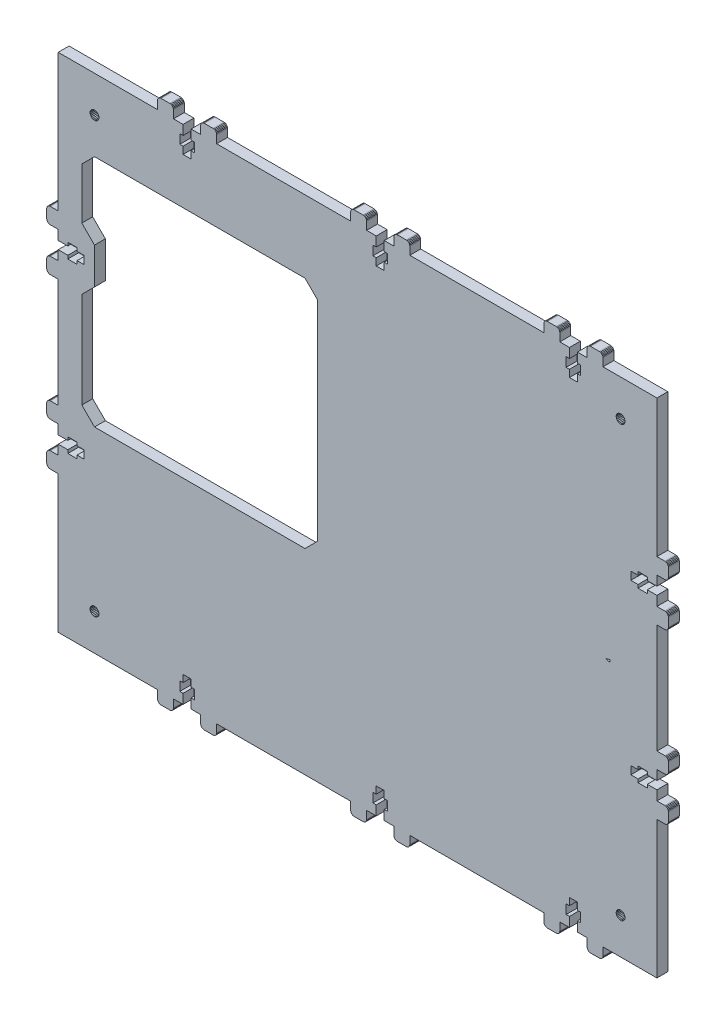
from build123d import *

# Parameters (mm, degrees)
BOSS_EXTRUDE1_DEPTH = 6


with BuildPart() as part:
    # Sketch1 → Boss-Extrude1 (new body)
    with BuildSketch(Plane.XY):
        Polygon((-90.633022684, 287.977715312), (-85.333023862, 287.977715312), (-85.333023862, 282.677718057), (-80.983025971, 282.677718057), (-80.465387881, 282.60956971), (-79.983025971, 282.409768865), (-79.568812409, 282.091931619), (-79.250975164, 281.677718057), (-79.051174319, 281.195356147), (-78.983025971, 280.677718057), (-78.983025971, 275.877723615), (-79.051174319, 275.360085525), (-79.250975164, 274.877723615), (-79.568812409, 274.463510052), (-79.983025971, 274.145672807), (-80.465387881, 273.945871962), (-80.983025971, 273.877723615), (-85.333023862, 273.877723615), (-85.333023862, 213.677737651), (-80.983025971, 213.677737651), (-80.465387881, 213.609589304), (-79.983025971, 213.409788459), (-79.568812409, 213.091951214), (-79.250975164, 212.677737651), (-79.051174319, 212.195375742), (-78.983025971, 211.677737651), (-78.983025971, 206.877741686), (-79.051174319, 206.360103596), (-79.250975164, 205.877741686), (-79.568812409, 205.463528124), (-79.983025971, 205.145690879), (-80.465387881, 204.945890034), (-80.983025971, 204.877741686), (-85.333023862, 204.877741686), (-85.333023862, 199.57774968), (-90.633022684, 199.57774968), (-90.633022684, 201.377747911), (-95.733020449, 201.377747911), (-95.733020449, 199.57774968), (-99.683020271, 199.57774968), (-99.683020271, 195.177745008), (-95.733020449, 195.177745008), (-95.733020449, 193.377746776), (-90.633022684, 193.377746776), (-90.633022684, 195.177745008), (-85.333023862, 195.177745008), (-85.333023862, 189.877747753), (-80.983025971, 189.877747753), (-80.465387881, 189.809599406), (-79.983025971, 189.609798561), (-79.568812409, 189.291961315), (-79.250975164, 188.877747753), (-79.051174319, 188.395385843), (-78.983025971, 187.877747753), (-78.983025971, 183.077753311), (-79.051174319, 182.560115221), (-79.250975164, 182.077753311), (-79.568812409, 181.663539748), (-79.983025971, 181.345702503), (-80.465387881, 181.145901658), (-80.983025971, 181.077753311), (-85.333023862, 181.077753311), (-85.333023862, 105.377776784), (-115.033018835, 105.377776784), (-115.033018835, 101.027778892), (-115.101167182, 100.510140802), (-115.300968027, 100.027778892), (-115.618805272, 99.61356533), (-116.033018835, 99.295728085), (-116.515380745, 99.09592724), (-117.033018835, 99.027778892), (-121.8330148, 99.027778892), (-122.35065289, 99.09592724), (-122.8330148, 99.295728085), (-123.247228362, 99.61356533), (-123.565065607, 100.027778892), (-123.764866452, 100.510140802), (-123.8330148, 101.027778892), (-123.8330148, 105.377776784), (-129.133006807, 105.377776784), (-129.133006807, 110.677775605), (-127.333008575, 110.677775605), (-127.333008575, 115.77777337), (-129.133006807, 115.77777337), (-129.133006807, 119.727773192), (-133.533011478, 119.727773192), (-133.533011478, 115.77777337), (-135.33300971, 115.77777337), (-135.33300971, 110.677775605), (-133.533011478, 110.677775605), (-133.533011478, 105.377776784), (-138.833008733, 105.377776784), (-138.833008733, 101.027778892), (-138.901157081, 100.510140802), (-139.100957926, 100.027778892), (-139.418795171, 99.61356533), (-139.833008733, 99.295728085), (-140.315370643, 99.09592724), (-140.833008733, 99.027778892), (-145.633003175, 99.027778892), (-146.150641266, 99.09592724), (-146.633003175, 99.295728085), (-147.047216738, 99.61356533), (-147.365053983, 100.027778892), (-147.564854828, 100.510140802), (-147.633003175, 101.027778892), (-147.633003175, 105.377776784), (-221.482984771, 105.377776784), (-221.482984771, 101.027778892), (-221.551133118, 100.510140802), (-221.750933963, 100.027778892), (-222.068771208, 99.61356533), (-222.482984771, 99.295728085), (-222.965346681, 99.09592724), (-223.482984771, 99.027778892), (-228.282980736, 99.027778892), (-228.800618826, 99.09592724), (-229.282980736, 99.295728085), (-229.697194298, 99.61356533), (-230.015031543, 100.027778892), (-230.214832388, 100.510140802), (-230.282980736, 101.027778892), (-230.282980736, 105.377776784), (-235.582972743, 105.377776784), (-235.582972743, 110.677775605), (-233.782974511, 110.677775605), (-233.782974511, 115.77777337), (-235.582972743, 115.77777337), (-235.582972743, 119.727773192), (-239.982977414, 119.727773192), (-239.982977414, 115.77777337), (-241.782975646, 115.77777337), (-241.782975646, 110.677775605), (-239.982977414, 110.677775605), (-239.982977414, 105.377776784), (-245.282974669, 105.377776784), (-245.282974669, 101.027778892), (-245.351123017, 100.510140802), (-245.550923862, 100.027778892), (-245.868761107, 99.61356533), (-246.282974669, 99.295728085), (-246.765336579, 99.09592724), (-247.282974669, 99.027778892), (-252.082969111, 99.027778892), (-252.600607202, 99.09592724), (-253.082969111, 99.295728085), (-253.497182674, 99.61356533), (-253.815019919, 100.027778892), (-254.014820764, 100.510140802), (-254.082969111, 101.027778892), (-254.082969111, 105.377776784), (-327.932950707, 105.377776784), (-327.932950707, 101.027778892), (-328.001099054, 100.510140802), (-328.200899899, 100.027778892), (-328.518737144, 99.61356533), (-328.932950707, 99.295728085), (-329.415312617, 99.09592724), (-329.932950707, 99.027778892), (-334.732946672, 99.027778892), (-335.250584762, 99.09592724), (-335.732946672, 99.295728085), (-336.147160234, 99.61356533), (-336.464997479, 100.027778892), (-336.664798324, 100.510140802), (-336.732946672, 101.027778892), (-336.732946672, 105.377776784), (-342.032938679, 105.377776784), (-342.032938679, 110.677775605), (-340.232940447, 110.677775605), (-340.232940447, 115.77777337), (-342.032938679, 115.77777337), (-342.032938679, 119.727773192), (-346.43294335, 119.727773192), (-346.43294335, 115.77777337), (-348.232941582, 115.77777337), (-348.232941582, 110.677775605), (-346.43294335, 110.677775605), (-346.43294335, 105.377776784), (-351.732940605, 105.377776784), (-351.732940605, 101.027778892), (-351.801088953, 100.510140802), (-352.000889798, 100.027778892), (-352.318727043, 99.61356533), (-352.732940605, 99.295728085), (-353.215302515, 99.09592724), (-353.732940605, 99.027778892), (-358.532935047, 99.027778892), (-359.050573138, 99.09592724), (-359.532935047, 99.295728085), (-359.94714861, 99.61356533), (-360.264985855, 100.027778892), (-360.4647867, 100.510140802), (-360.532935047, 101.027778892), (-360.532935047, 105.377776784), (-415.232918294, 105.377776784), (-415.232918294, 181.077757036), (-419.582916186, 181.077757036), (-420.100554276, 181.145905383), (-420.582916186, 181.345706228), (-420.997129748, 181.663543474), (-421.314966993, 182.077757036), (-421.514767838, 182.560118946), (-421.582916186, 183.077757036), (-421.582916186, 187.877753001), (-421.514767838, 188.395391091), (-421.314966993, 188.877753001), (-420.997129748, 189.291966563), (-420.582916186, 189.609803809), (-420.100554276, 189.809604654), (-419.582916186, 189.877753001), (-415.232918294, 189.877753001), (-415.232918294, 195.177745008), (-409.932919473, 195.177745008), (-409.932919473, 193.377746776), (-404.832921708, 193.377746776), (-404.832921708, 195.177745008), (-400.882921886, 195.177745008), (-400.882921886, 199.57774968), (-404.832921708, 199.57774968), (-404.832921708, 201.377747911), (-409.932919473, 201.377747911), (-409.932919473, 199.57774968), (-415.232918294, 199.57774968), (-415.232918294, 204.877746934), (-419.582916186, 204.877746934), (-420.100554276, 204.945895282), (-420.582916186, 205.145696127), (-420.997129748, 205.463533372), (-421.314966993, 205.877746934), (-421.514767838, 206.360108844), (-421.582916186, 206.877746934), (-421.582916186, 211.677741377), (-421.514767838, 212.195379467), (-421.314966993, 212.677741377), (-420.997129748, 213.091954939), (-420.582916186, 213.409792184), (-420.100554276, 213.609593029), (-419.582916186, 213.677741377), (-415.232918294, 213.677741377), (-415.232918294, 273.87772734), (-419.582916186, 273.87772734), (-420.100554276, 273.945875687), (-420.582916186, 274.145676532), (-420.997129748, 274.463513778), (-421.314966993, 274.87772734), (-421.514767838, 275.36008925), (-421.582916186, 275.87772734), (-421.582916186, 280.677723305), (-421.514767838, 281.195361395), (-421.314966993, 281.677723305), (-420.997129748, 282.091936867), (-420.582916186, 282.409774113), (-420.100554276, 282.609574958), (-419.582916186, 282.677723305), (-415.232918294, 282.677723305), (-415.232918294, 287.977715312), (-409.932919473, 287.977715312), (-409.932919473, 286.17771708), (-404.832921708, 286.17771708), (-404.832921708, 287.977715312), (-400.882921886, 287.977715312), (-400.882921886, 292.377719984), (-404.832921708, 292.377719984), (-404.832921708, 294.177718215), (-409.932919473, 294.177718215), (-409.932919473, 292.377719984), (-415.232918294, 292.377719984), (-415.232918294, 297.677717238), (-419.582916186, 297.677717238), (-420.100554276, 297.745865586), (-420.582916186, 297.945666431), (-420.997129748, 298.263503676), (-421.314966993, 298.677717238), (-421.514767838, 299.160079148), (-421.582916186, 299.677717238), (-421.582916186, 304.477711681), (-421.514767838, 304.995349771), (-421.314966993, 305.477711681), (-420.997129748, 305.891925243), (-420.582916186, 306.209762488), (-420.100554276, 306.409563333), (-419.582916186, 306.477711681), (-415.232918294, 306.477711681), (-415.232918294, 382.177688208), (-360.532931322, 382.177688208), (-360.532931322, 386.527686099), (-360.464782975, 387.045324189), (-360.26498213, 387.527686099), (-359.947144885, 387.941899661), (-359.532931322, 388.259736906), (-359.050569412, 388.459537751), (-358.532931322, 388.527686099), (-353.732935357, 388.527686099), (-353.215297267, 388.459537751), (-352.732935357, 388.259736906), (-352.318721795, 387.941899661), (-352.00088455, 387.527686099), (-351.801083705, 387.045324189), (-351.732935357, 386.527686099), (-351.732935357, 382.177688208), (-346.43294335, 382.177688208), (-346.43294335, 376.877689386), (-348.232941582, 376.877689386), (-348.232941582, 371.777691621), (-346.43294335, 371.777691621), (-346.43294335, 367.827691799), (-342.032938679, 367.827691799), (-342.032938679, 371.777691621), (-340.232940447, 371.777691621), (-340.232940447, 376.877689386), (-342.032938679, 376.877689386), (-342.032938679, 382.177688208), (-336.732941424, 382.177688208), (-336.732941424, 386.527686099), (-336.664793076, 387.045324189), (-336.464992231, 387.527686099), (-336.147154986, 387.941899661), (-335.732941424, 388.259736906), (-335.250579514, 388.459537751), (-334.732941424, 388.527686099), (-329.932946982, 388.527686099), (-329.415308891, 388.459537751), (-328.932946982, 388.259736906), (-328.518733419, 387.941899661), (-328.200896174, 387.527686099), (-328.001095329, 387.045324189), (-327.932946982, 386.527686099), (-327.932946982, 382.177688208), (-254.082965386, 382.177688208), (-254.082965386, 386.527686099), (-254.014817039, 387.045324189), (-253.815016194, 387.527686099), (-253.497178949, 387.941899661), (-253.082965386, 388.259736906), (-252.600603476, 388.459537751), (-252.082965386, 388.527686099), (-247.282969421, 388.527686099), (-246.765331331, 388.459537751), (-246.282969421, 388.259736906), (-245.868755859, 387.941899661), (-245.550918614, 387.527686099), (-245.351117769, 387.045324189), (-245.282969421, 386.527686099), (-245.282969421, 382.177688208), (-239.982977414, 382.177688208), (-239.982977414, 376.877689386), (-241.782975646, 376.877689386), (-241.782975646, 371.777691621), (-239.982977414, 371.777691621), (-239.982977414, 367.827691799), (-235.582972743, 367.827691799), (-235.582972743, 371.777691621), (-233.782974511, 371.777691621), (-233.782974511, 376.877689386), (-235.582972743, 376.877689386), (-235.582972743, 382.177688208), (-230.282975488, 382.177688208), (-230.282975488, 386.527686099), (-230.21482714, 387.045324189), (-230.015026295, 387.527686099), (-229.69718905, 387.941899661), (-229.282975488, 388.259736906), (-228.800613578, 388.459537751), (-228.282975488, 388.527686099), (-223.482981046, 388.527686099), (-222.965342955, 388.459537751), (-222.482981046, 388.259736906), (-222.068767483, 387.941899661), (-221.750930238, 387.527686099), (-221.551129393, 387.045324189), (-221.482981046, 386.527686099), (-221.482981046, 382.177688208), (-147.63299945, 382.177688208), (-147.63299945, 386.527686099), (-147.564851103, 387.045324189), (-147.365050258, 387.527686099), (-147.047213013, 387.941899661), (-146.63299945, 388.259736906), (-146.15063754, 388.459537751), (-145.63299945, 388.527686099), (-140.833003485, 388.527686099), (-140.315365395, 388.459537751), (-139.833003485, 388.259736906), (-139.418789923, 387.941899661), (-139.100952678, 387.527686099), (-138.901151833, 387.045324189), (-138.833003485, 386.527686099), (-138.833003485, 382.177688208), (-133.533011478, 382.177688208), (-133.533011478, 376.877689386), (-135.33300971, 376.877689386), (-135.33300971, 371.777691621), (-133.533011478, 371.777691621), (-133.533011478, 367.827691799), (-129.133006807, 367.827691799), (-129.133006807, 371.777691621), (-127.333008575, 371.777691621), (-127.333008575, 376.877689386), (-129.133006807, 376.877689386), (-129.133006807, 382.177688208), (-123.833009552, 382.177688208), (-123.833009552, 386.527686099), (-123.764861204, 387.045324189), (-123.565060359, 387.527686099), (-123.247223114, 387.941899661), (-122.833009552, 388.259736906), (-122.350647642, 388.459537751), (-121.833009552, 388.527686099), (-117.03301511, 388.527686099), (-116.515377019, 388.459537751), (-116.03301511, 388.259736906), (-115.618801547, 387.941899661), (-115.300964302, 387.527686099), (-115.101163457, 387.045324189), (-115.03301511, 386.527686099), (-115.03301511, 382.177688208), (-85.333023862, 382.177688208), (-85.333023862, 306.477707955), (-80.983025971, 306.477707955), (-80.465387881, 306.409559608), (-79.983025971, 306.209758763), (-79.568812409, 305.891921518), (-79.250975164, 305.477707955), (-79.051174319, 304.995346046), (-78.983025971, 304.477707955), (-78.983025971, 299.67771199), (-79.051174319, 299.1600739), (-79.250975164, 298.67771199), (-79.568812409, 298.263498428), (-79.983025971, 297.945661183), (-80.465387881, 297.745860338), (-80.983025971, 297.67771199), (-85.333023862, 297.67771199), (-85.333023862, 292.377719984), (-90.633022684, 292.377719984), (-90.633022684, 294.177718215), (-95.733020449, 294.177718215), (-95.733020449, 292.377719984), (-99.683020271, 292.377719984), (-99.683020271, 287.977715312), (-95.733020449, 287.977715312), (-95.733020449, 286.17771708), (-90.633022684, 286.17771708), align=None)
        Polygon((-396.457918294, 123.256014544), (-395.867024955, 123.011258509), (-395.232918294, 122.927776784), (-394.598811634, 123.011258509), (-394.007918294, 123.256014544), (-393.500506681, 123.64536517), (-393.111156055, 124.152776784), (-392.86640002, 124.743670123), (-392.782918294, 125.377776784), (-392.86640002, 126.011883444), (-393.111156055, 126.602776784), (-393.500506681, 127.110188398), (-394.007918294, 127.499539023), (-394.598811634, 127.744295058), (-395.232918294, 127.827776784), (-395.867024955, 127.744295058), (-396.457918294, 127.499539023), (-396.965329908, 127.110188398), (-397.354680534, 126.602776784), (-397.599436569, 126.011883444), (-397.682918294, 125.377776784), (-397.599436569, 124.743670123), (-397.354680534, 124.152776784), (-396.965329908, 123.64536517), align=None, mode=Mode.SUBTRACT)
        Polygon((-395.232918294, 359.727688208), (-394.598811634, 359.811169933), (-394.007918294, 360.055925968), (-393.500506681, 360.445276594), (-393.111156055, 360.952688208), (-392.86640002, 361.543581547), (-392.782918294, 362.177688208), (-392.86640002, 362.811794868), (-393.111156055, 363.402688208), (-393.500506681, 363.910099822), (-394.007918294, 364.299450447), (-394.598811634, 364.544206482), (-395.232918294, 364.627688208), (-395.867024955, 364.544206482), (-396.457918294, 364.299450447), (-396.965329908, 363.910099822), (-397.354680534, 363.402688208), (-397.599436569, 362.811794868), (-397.682918294, 362.177688208), (-397.599436569, 361.543581547), (-397.354680534, 360.952688208), (-396.965329908, 360.445276594), (-396.457918294, 360.055925968), (-395.867024955, 359.811169933), align=None, mode=Mode.SUBTRACT)
        Polygon((-105.333023862, 359.727688208), (-105.967130523, 359.811169933), (-106.558023862, 360.055925968), (-107.065435476, 360.445276594), (-107.454786102, 360.952688208), (-107.699542137, 361.543581547), (-107.783023862, 362.177688208), (-107.699542137, 362.811794868), (-107.454786102, 363.402688208), (-107.065435476, 363.910099822), (-106.558023862, 364.299450447), (-105.967130523, 364.544206482), (-105.333023862, 364.627688208), (-104.698917202, 364.544206482), (-104.108023862, 364.299450447), (-103.600612249, 363.910099822), (-103.211261623, 363.402688208), (-102.966505588, 362.811794868), (-102.883023862, 362.177688208), (-102.966505588, 361.543581547), (-103.211261623, 360.952688208), (-103.600612249, 360.445276594), (-104.108023862, 360.055925968), (-104.698917202, 359.811169933), align=None, mode=Mode.SUBTRACT)
        Polygon((-105.333023862, 122.927776784), (-105.967130523, 123.011258509), (-106.558023862, 123.256014544), (-107.065435476, 123.64536517), (-107.454786102, 124.152776784), (-107.699542137, 124.743670123), (-107.783023862, 125.377776784), (-107.699542137, 126.011883444), (-107.454786102, 126.602776784), (-107.065435476, 127.110188398), (-106.558023862, 127.499539023), (-105.967130523, 127.744295058), (-105.333023862, 127.827776784), (-104.698917202, 127.744295058), (-104.108023862, 127.499539023), (-103.600612249, 127.110188398), (-103.211261623, 126.602776784), (-102.966505588, 126.011883444), (-102.883023862, 125.377776784), (-102.966505588, 124.743670123), (-103.211261623, 124.152776784), (-103.600612249, 123.64536517), (-104.108023862, 123.256014544), (-104.698917202, 123.011258509), align=None, mode=Mode.SUBTRACT)
        Polygon((-272.229386492, 335.377688208), (-272.229386492, 220.377688208), (-279.229386492, 213.377688208), (-395.229386492, 213.377688208), (-402.229386492, 220.377688208), (-402.229386492, 273.177717648), (-395.229386492, 280.177717648), (-395.229386492, 300.177717648), (-402.229386492, 307.177717648), (-402.229386492, 335.377688208), (-395.229386492, 342.377688208), (-279.229386492, 342.377688208), align=None, mode=Mode.SUBTRACT)
        Polygon((-109.331960623, 244.812597403), (-113.645985013, 243.688693059), (-109.331960623, 242.627241077), (-111.148938519, 243.076793287), (-111.148938519, 244.338083303), align=None, mode=Mode.SUBTRACT)
    extrude(amount=BOSS_EXTRUDE1_DEPTH)


solid = part.part
